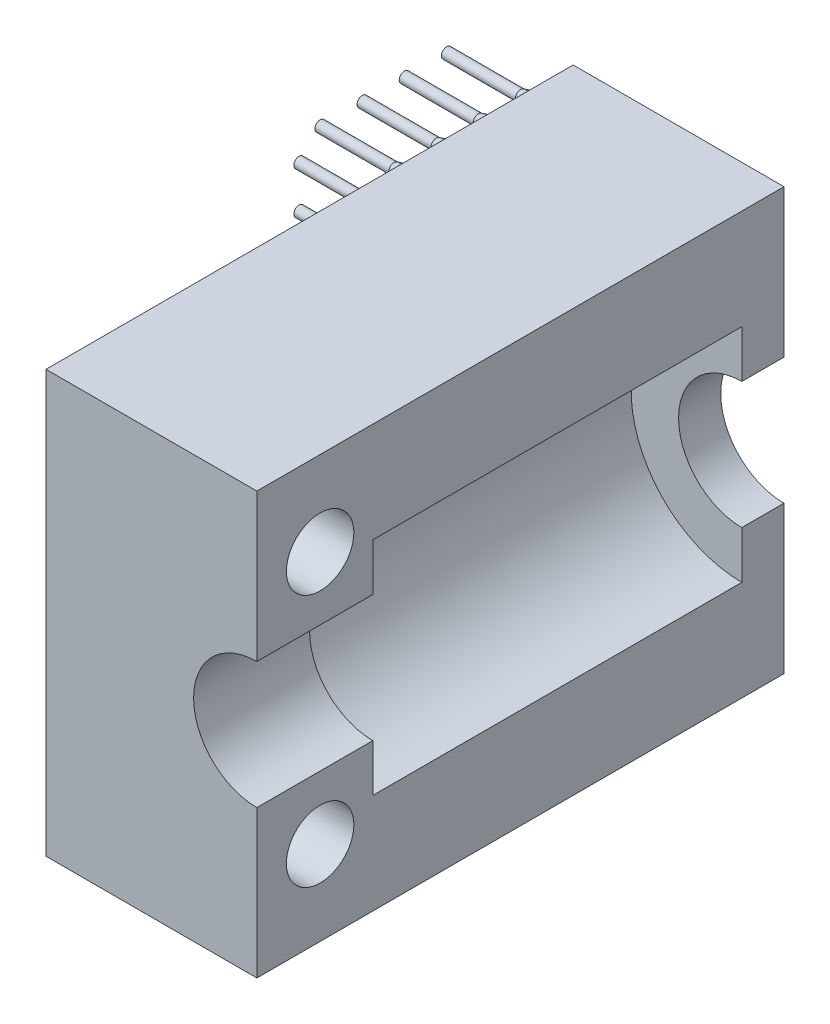
from build123d import *

# Parameters (mm, degrees)
EXTRUDE_1_DEPTH                     = 25
SKETCH_2_R                          = 0.25
EXTRUDE_2_DEPTH                     = 5
CHAMFER_1_SIZE                      = 0.4
CHAMFER_1_SIZE2                     = 1.492820323
PATTERN_LINEAR_1_COUNT              = 4
PATTERN_LINEAR_1_PITCH              = 2
PATTERN_LINEAR_1_COUNT_DIR2         = 9
PATTERN_LINEAR_1_PITCH_DIR2         = 2
CHAMFER_1_OF_PATTERN_LINEAR_1_SIZE2 = 1.492820323
CHAMFER_1_OF_PATTERN_LINEAR_1_SIZE  = 0.4
SKETCH_3_R                          = 5.25
CUT_EXTRUDE_1_DEPTH                 = 17.5
SKETCH_4_R                          = 1.6
CUT_EXTRUDE_2_DEPTH                 = 16


with BuildPart() as part:
    # ｽｹｯﾁ1 → ﾎﾞｽ - 押し出し1 (new body)
    with BuildSketch(Plane.XY):
        with BuildLine():
            Line((0, 10), (-10, 10))
            Line((-10, 10), (-10, -10))
            Line((-10, -10), (0, -10))
            Line((0, -10), (0, -3))
            ThreePointArc((0, -3), (-3, 0), (0, 3))
            Line((0, 3), (0, 10))
        make_face()
    extrude(amount=EXTRUDE_1_DEPTH)

    # ｽｹｯﾁ2 → ﾎﾞｽ - 押し出し2 (add)
    with BuildSketch(Plane.ZY.offset(10)):
        with Locations((1, 8.5)):
            Circle(SKETCH_2_R)
        with Locations((2, 7.5)):
            Circle(SKETCH_2_R)
    extrude_2 = extrude(amount=EXTRUDE_2_DEPTH)

    # 面取り1
    chamfer_1_edges = [part.edges().sort_by_distance(p)[0] for p in [
        (-10, 8.5, 0.75),
        (-10, 7.5, 1.75),
    ]]
    chamfer_1_side = [part.faces().sort_by_distance(p)[0] for p in [
        (-10, -0.006288124, 12.50864617),
    ]]
    chamfer(chamfer_1_edges, length=CHAMFER_1_SIZE, length2=CHAMFER_1_SIZE2, reference=chamfer_1_side[0])

    # 直線ﾊﾟﾀｰﾝ1: Extrude 2 4 × 9
    with Locations(*[(0, -j * PATTERN_LINEAR_1_PITCH_DIR2, i * PATTERN_LINEAR_1_PITCH) for i in range(PATTERN_LINEAR_1_COUNT) for j in range(PATTERN_LINEAR_1_COUNT_DIR2) if (i, j) != (0, 0)]):
        add(extrude_2)

    # 面取り1 of 直線ﾊﾟﾀｰﾝ1
    chamfer_1_of_pattern_linear_1_edges = [part.edges().sort_by_distance(p)[0] for p in [
        (-10, 6.5, 0.75),
        (-10, 5.5, 1.75),
        (-10, 4.5, 0.75),
        (-10, 3.5, 1.75),
        (-10, 2.5, 0.75),
        (-10, 1.5, 1.75),
        (-10, 0.5, 0.75),
        (-10, -0.5, 1.75),
        (-10, -1.5, 0.75),
        (-10, -2.5, 1.75),
        (-10, -3.5, 0.75),
        (-10, -4.5, 1.75),
        (-10, -5.5, 0.75),
        (-10, -6.5, 1.75),
        (-10, -7.5, 0.75),
        (-10, -8.5, 1.75),
        (-10, 8.5, 2.75),
        (-10, 7.5, 3.75),
        (-10, 6.5, 2.75),
        (-10, 5.5, 3.75),
        (-10, 4.5, 2.75),
        (-10, 3.5, 3.75),
        (-10, 2.5, 2.75),
        (-10, 1.5, 3.75),
        (-10, 0.5, 2.75),
        (-10, -0.5, 3.75),
        (-10, -1.5, 2.75),
        (-10, -2.5, 3.75),
        (-10, -3.5, 2.75),
        (-10, -4.5, 3.75),
        (-10, -5.5, 2.75),
        (-10, -6.5, 3.75),
        (-10, -7.5, 2.75),
        (-10, -8.5, 3.75),
        (-10, 8.5, 4.75),
        (-10, 7.5, 5.75),
        (-10, 6.5, 4.75),
        (-10, 5.5, 5.75),
        (-10, 4.5, 4.75),
        (-10, 3.5, 5.75),
        (-10, 2.5, 4.75),
        (-10, 1.5, 5.75),
        (-10, 0.5, 4.75),
        (-10, -0.5, 5.75),
        (-10, -1.5, 4.75),
        (-10, -2.5, 5.75),
        (-10, -3.5, 4.75),
        (-10, -4.5, 5.75),
        (-10, -5.5, 4.75),
        (-10, -6.5, 5.75),
        (-10, -7.5, 4.75),
        (-10, -8.5, 5.75),
        (-10, 8.5, 6.75),
        (-10, 7.5, 7.75),
        (-10, 6.5, 6.75),
        (-10, 5.5, 7.75),
        (-10, 4.5, 6.75),
        (-10, 3.5, 7.75),
        (-10, 2.5, 6.75),
        (-10, 1.5, 7.75),
        (-10, 0.5, 6.75),
        (-10, -0.5, 7.75),
        (-10, -1.5, 6.75),
        (-10, -2.5, 7.75),
        (-10, -3.5, 6.75),
        (-10, -4.5, 7.75),
        (-10, -5.5, 6.75),
        (-10, -6.5, 7.75),
        (-10, -7.5, 6.75),
        (-10, -8.5, 7.75),
    ]]
    chamfer(chamfer_1_of_pattern_linear_1_edges, length=CHAMFER_1_OF_PATTERN_LINEAR_1_SIZE, length2=CHAMFER_1_OF_PATTERN_LINEAR_1_SIZE2)

    # ｽｹｯﾁ3 → ｶｯﾄ - 押し出し1 (cut)
    with BuildSketch(Plane(origin=(0, 0, 2), x_dir=(-1, 0, 0), z_dir=(0, 0, -1))):
        Circle(SKETCH_3_R)
    extrude(amount=-CUT_EXTRUDE_1_DEPTH, mode=Mode.SUBTRACT)

    # ｽｹｯﾁ4 → ｶｯﾄ - 押し出し2 (cut, through all)
    with BuildSketch(Plane(origin=(0, 0, 0), x_dir=(0, 0, -1), z_dir=(1, 0, 0))):
        with Locations((-22, 6)):
            Circle(SKETCH_4_R)
        with Locations((-22, -6)):
            Circle(SKETCH_4_R)
    extrude(amount=-CUT_EXTRUDE_2_DEPTH, mode=Mode.SUBTRACT)


solid = part.part
